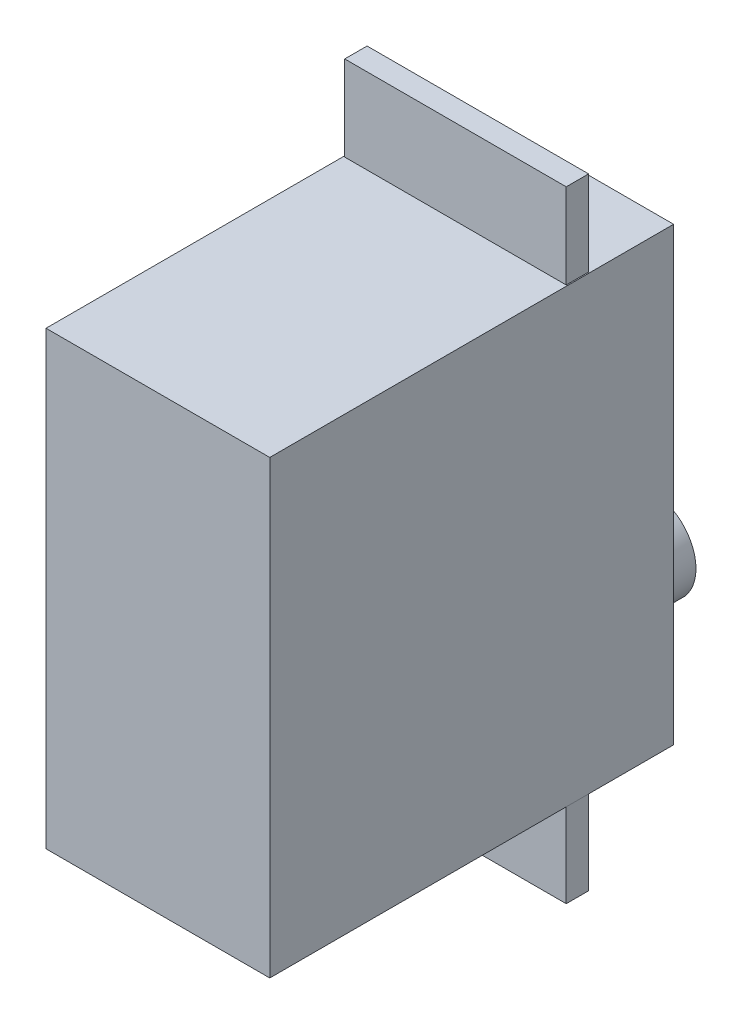
from build123d import *

# Parameters (mm, degrees)
ESQUISSE1_W        = 20
ESQUISSE1_H        = 40.3
BOSS_EXTRU_1_DEPTH = 36.1
ESQUISSE3_W        = 19.8
ESQUISSE3_H        = 2
BOSS_EXTRU_3_DEPTH = 7.6
ESQUISSE5_W        = 19.8
ESQUISSE5_H        = 2
BOSS_EXTRU_4_DEPTH = 7.6
ESQUISSE6_R        = 4
BOSS_EXTRU_5_DEPTH = 8


with BuildPart() as part:
    # Esquisse1 → Boss.-Extru.1 (new body)
    with BuildSketch(Plane.XY):
        Rectangle(ESQUISSE1_W, ESQUISSE1_H)
    extrude(amount=BOSS_EXTRU_1_DEPTH)

    # Esquisse3 → Boss.-Extru.3 (add)
    with BuildSketch(Plane(origin=(-10, -20.15, 0), x_dir=(1, 0, 0), z_dir=(0, -1, 0))):
        with Locations((10, 8.5)):
            Rectangle(ESQUISSE3_W, ESQUISSE3_H)
    extrude(amount=BOSS_EXTRU_3_DEPTH)

    # Esquisse5 → Boss.-Extru.4 (add)
    with BuildSketch(Plane(origin=(0, 20.15, 0), x_dir=(1, 0, 0), z_dir=(0, 1, 0))):
        with Locations((0, -8.5)):
            Rectangle(ESQUISSE5_W, ESQUISSE5_H)
    extrude(amount=BOSS_EXTRU_4_DEPTH)

    # Esquisse6 → Boss.-Extru.5 (add)
    with BuildSketch(Plane(origin=(0, 0, 0), x_dir=(-1, 0, 0), z_dir=(0, 0, -1))):
        with Locations(Location((0, -13.5, 0), (0, 0, 180))):  # turned: the seam where the file's is
            Circle(ESQUISSE6_R)
    extrude(amount=BOSS_EXTRU_5_DEPTH)


solid = part.part
